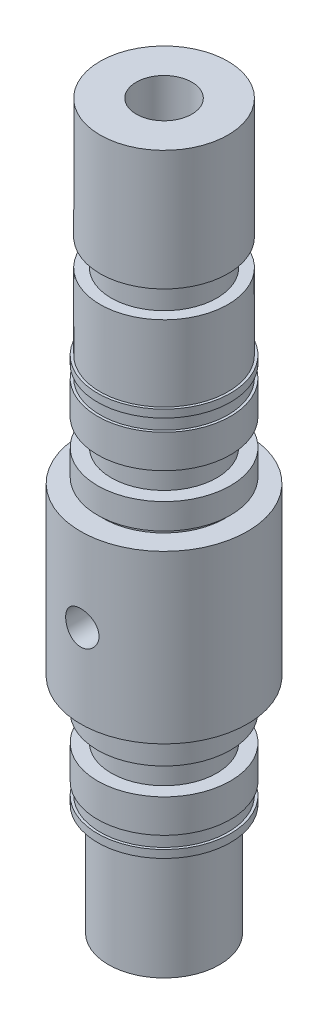
from build123d import *
from build123d.topology import SkipClean

# Parameters (mm, degrees)
SKETCH3_W           = 1.225
SKETCH3_H           = 2.4
SKETCH4_R           = 1.5
CUT_EXTRUDE2_DEPTH  = 10
SKETCH5_R           = 5
BOSS_EXTRUDE1_DEPTH = 10
SKETCH6_W           = 0.5
SKETCH6_H           = 0.5
SKETCH7_R           = 5.75
BOSS_EXTRUDE2_DEPTH = 20
SKETCH9_R           = 1.5
CUT_EXTRUDE4_DEPTH  = 39
SKETCH10_W          = 1.225
SKETCH10_H          = 2.4
SKETCH12_W          = 0.25
SKETCH12_H          = 1.1
SKETCH12_W_2        = 0.225
SKETCH14_R          = 2.5
CUT_EXTRUDE8_DEPTH  = 8


with BuildPart() as part:
    # Sketch1 → Revolve1 (revolve)
    with BuildSketch(Plane.XY):
        Polygon((0, 35), (-5.975, 35), (-5.975, 25), (-7.5, 25), (-7.5, 10), (-5.975, 10), (-5.975, 0), (0, 0), align=None)
    revolve(axis=Axis((0, 0, 0), (0, 1, 0)))

    # Sketch3 → Cut-Revolve1 (revolve, cut)
    with BuildSketch(Plane(origin=(0, 0, 0), x_dir=(0, 0, -1), z_dir=(1, 0, 0))):
        with Locations((-5.3625, 29)):
            Rectangle(SKETCH3_W, SKETCH3_H)
        with Locations((-5.3625, 6)):
            Rectangle(SKETCH3_W, SKETCH3_H)
    revolve(axis=Axis((0, 35, 0), (0, -1, 0)), mode=Mode.SUBTRACT)

    # Sketch4 → Cut-Extrude2 (cut)
    with BuildSketch(Plane.XY):
        with Locations((0, 17.5)):
            Circle(SKETCH4_R)
    extrude(amount=CUT_EXTRUDE2_DEPTH, mode=Mode.SUBTRACT)

    # Sketch5 → Boss-Extrude1 (add)
    with BuildSketch(Plane.XZ):
        Circle(SKETCH5_R)
    extrude(amount=BOSS_EXTRUDE1_DEPTH)

    # Sketch6 → Cut-Revolve2 (revolve, cut)
    with BuildSketch(Plane(origin=(0, 0, 0), x_dir=(0, 0, -1), z_dir=(1, 0, 0))):
        with Locations((5.725, 9.75)):
            Rectangle(SKETCH6_W, SKETCH6_H)
        with Locations((5.725, 25.25)):
            Rectangle(SKETCH6_W, SKETCH6_H)
    revolve(axis=Axis((0, 0, 0), (0, 1, 0)), mode=Mode.SUBTRACT)

    # Sketch7 → Boss-Extrude2 (add)
    with BuildSketch(Plane(origin=(0, 35, 0), x_dir=(1, 0, 0), z_dir=(0, 1, 0))):
        Circle(SKETCH7_R)
    extrude(amount=BOSS_EXTRUDE2_DEPTH)

    # Sketch9 → Cut-Extrude4 (cut)
    with SkipClean():  # the faces are left unmerged after this step: merging them gives an invalid solid
        with BuildSketch(Plane(origin=(0, 55, 0), x_dir=(1, 0, 0), z_dir=(0, 1, 0))):
            Circle(SKETCH9_R)
        extrude(amount=-CUT_EXTRUDE4_DEPTH, mode=Mode.SUBTRACT)

    # Sketch10 → Cut-Revolve3 (revolve, cut)
    with SkipClean():  # the faces are left unmerged after this step: merging them gives an invalid solid
        with BuildSketch(Plane(origin=(0, 0, 0), x_dir=(0, 0, -1), z_dir=(1, 0, 0))):
            with Locations((-5.3625, 43)):
                Rectangle(SKETCH10_W, SKETCH10_H)
        revolve(axis=Axis((0, 55, 0), (0, -1, 0)), mode=Mode.SUBTRACT)

    # Sketch12 → Cut-Revolve4 (revolve, cut)
    with SkipClean():  # the faces are left unmerged after this step: merging them gives an invalid solid
        with BuildSketch(Plane.XY):
            with Locations((-5.875, 33.75)):
                Rectangle(SKETCH12_W, SKETCH12_H)
            with Locations((-5.8625, 1.25)):
                Rectangle(SKETCH12_W_2, SKETCH12_H)
        revolve(axis=Axis((0, 0, 0), (0, 1, 0)), mode=Mode.SUBTRACT)

    # Sketch14 → Cut-Extrude8 (cut)
    with SkipClean():  # the faces are left unmerged after this step: merging them gives an invalid solid
        with BuildSketch(Plane(origin=(0, 55, 0), x_dir=(1, 0, 0), z_dir=(0, 1, 0))):
            Circle(SKETCH14_R)
        extrude(amount=-CUT_EXTRUDE8_DEPTH, mode=Mode.SUBTRACT)


solid = part.part
